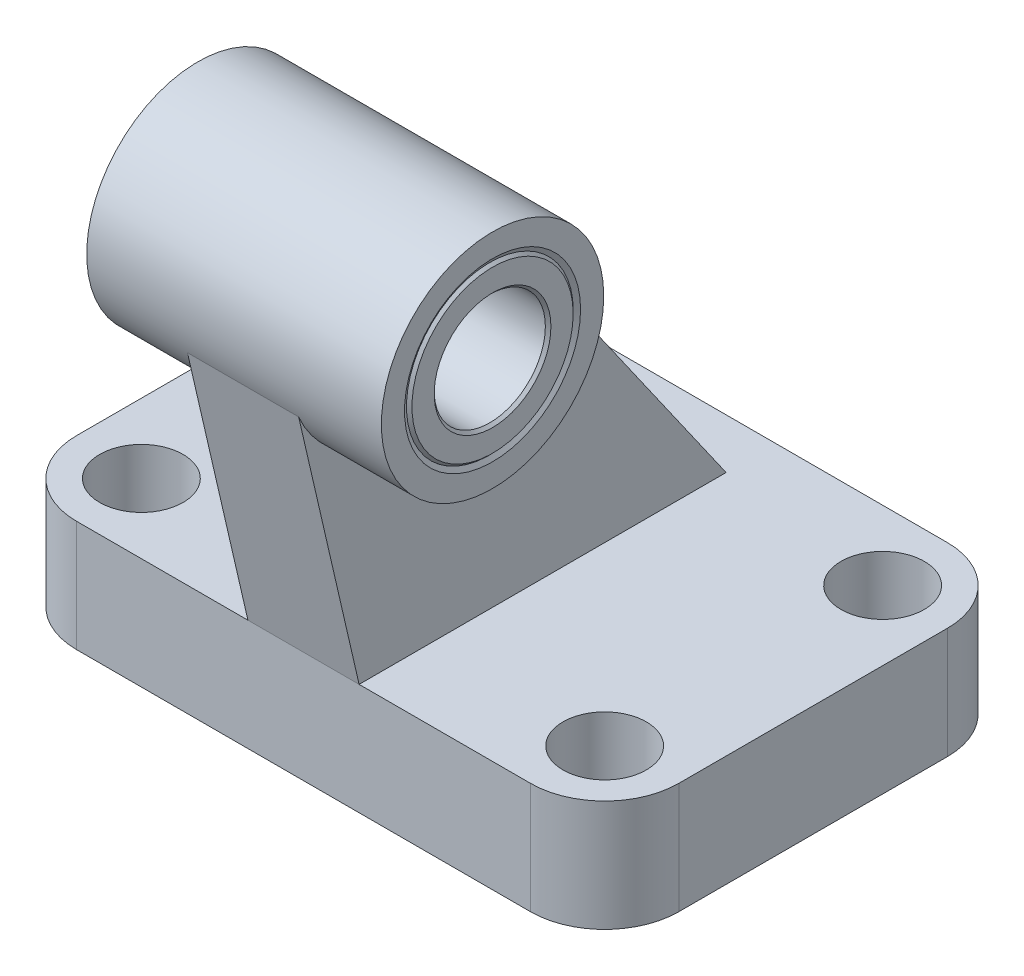
from build123d import *

# Parameters (mm, degrees)
BOSS_EXTRUDE1_DEPTH      = 12
BOSS_EXTRUDE2_DEPTH      = 6
BOSS_EXTRUDE2_DEPTH_BACK = 6
SKETCH3_R                = 12
BOSS_EXTRUDE3_DEPTH      = 15.9
BOSS_EXTRUDE3_DEPTH_BACK = 15.9
SKETCH4_W                = 4.5
SKETCH4_H                = 12
SKETCH5_W                = 4.5
SKETCH5_H                = 12
SKETCH6_W                = 4.5
SKETCH6_H                = 12
SKETCH7_W                = 4.5
SKETCH7_H                = 12


with BuildPart() as part:
    # Sketch1 → Boss-Extrude1 (new body)
    with BuildSketch(Plane(origin=(0, 0, 0), x_dir=(1, 0, 0), z_dir=(0, 1, 0))):
        with BuildLine():
            Line((-24.5, -22.5), (24.5, -22.5))
            ThreePointArc((24.5, -22.5), (30.156854249, -20.156854249), (32.5, -14.5))
            Line((32.5, -14.5), (32.5, 14.5))
            ThreePointArc((32.5, 14.5), (30.156854249, 20.156854249), (24.5, 22.5))
            Line((24.5, 22.5), (-24.5, 22.5))
            ThreePointArc((-24.5, 22.5), (-30.156854249, 20.156854249), (-32.5, 14.5))
            Line((-32.5, 14.5), (-32.5, -14.5))
            ThreePointArc((-32.5, -14.5), (-30.156854249, -20.156854249), (-24.5, -22.5))
        make_face()
    extrude(amount=BOSS_EXTRUDE1_DEPTH)

    # Sketch2 → Boss-Extrude2 (add, two sides)
    with BuildSketch(Plane(origin=(0, 0, 0), x_dir=(0, 0, -1), z_dir=(1, 0, 0))) as boss_extrude2_sk:
        Polygon((-29.505410526, 42.343766684), (-22.5, 12), (17.106848761, 12), (-7.669916362, 47.384887724), align=None)
    extrude(amount=BOSS_EXTRUDE2_DEPTH)
    extrude(boss_extrude2_sk.sketch, amount=-BOSS_EXTRUDE2_DEPTH_BACK)

    # Sketch3 → Boss-Extrude3 (add, two sides)
    with BuildSketch(Plane(origin=(0, 0, 0), x_dir=(0, 0, -1), z_dir=(1, 0, 0))) as boss_extrude3_sk:
        with Locations((-18, 45)):
            Circle(SKETCH3_R)
    extrude(amount=BOSS_EXTRUDE3_DEPTH)
    extrude(boss_extrude3_sk.sketch, amount=-BOSS_EXTRUDE3_DEPTH_BACK)

    # Sketch4 → Cut-Revolve1 (revolve, cut)
    with BuildSketch(Plane.XY.offset(15)):
        with Locations((-27.25, 6)):
            Rectangle(SKETCH4_W, SKETCH4_H)
    revolve(axis=Axis((-25, 12, 15), (0, -1, 0)), mode=Mode.SUBTRACT)

    # Sketch5 → Cut-Revolve2 (revolve, cut)
    with BuildSketch(Plane.XY.offset(15)):
        with Locations((22.75, 6)):
            Rectangle(SKETCH5_W, SKETCH5_H)
    revolve(axis=Axis((25, 12, 15), (0, -1, 0)), mode=Mode.SUBTRACT)

    # Sketch6 → Cut-Revolve3 (revolve, cut)
    with BuildSketch(Plane.XY.offset(-15)):
        with Locations((-27.25, 6)):
            Rectangle(SKETCH6_W, SKETCH6_H)
    revolve(axis=Axis((-25, 12, -15), (0, -1, 0)), mode=Mode.SUBTRACT)

    # Sketch7 → Cut-Revolve4 (revolve, cut)
    with BuildSketch(Plane.XY.offset(-15)):
        with Locations((22.75, 6)):
            Rectangle(SKETCH7_W, SKETCH7_H)
    revolve(axis=Axis((25, 12, -15), (0, -1, 0)), mode=Mode.SUBTRACT)

    # Sketch8 → Cut-Revolve5 (revolve, cut)
    with BuildSketch(Plane.XY.offset(18)):
        Polygon((-15.9, 45), (-15.9, 54.5), (-15.611324865, 54), (15.611324865, 54), (15.9, 54.5), (15.9, 45), align=None)
    revolve(axis=Axis((15.9, 45, 18), (-1, 0, 0)), mode=Mode.SUBTRACT)

    # Sketch9 → Revolve1 (revolve)
    with BuildSketch(Plane.XY.offset(18)):
        Polygon((-15.9, 51.3), (-15.6, 51), (15.6, 51), (15.9, 51.3), (15.9, 53.7), (15.6, 54), (-15.6, 54), (-15.9, 53.7), align=None)
    revolve(axis=Axis((15.9, 45, 18), (-1, 0, 0)))


solid = part.part
